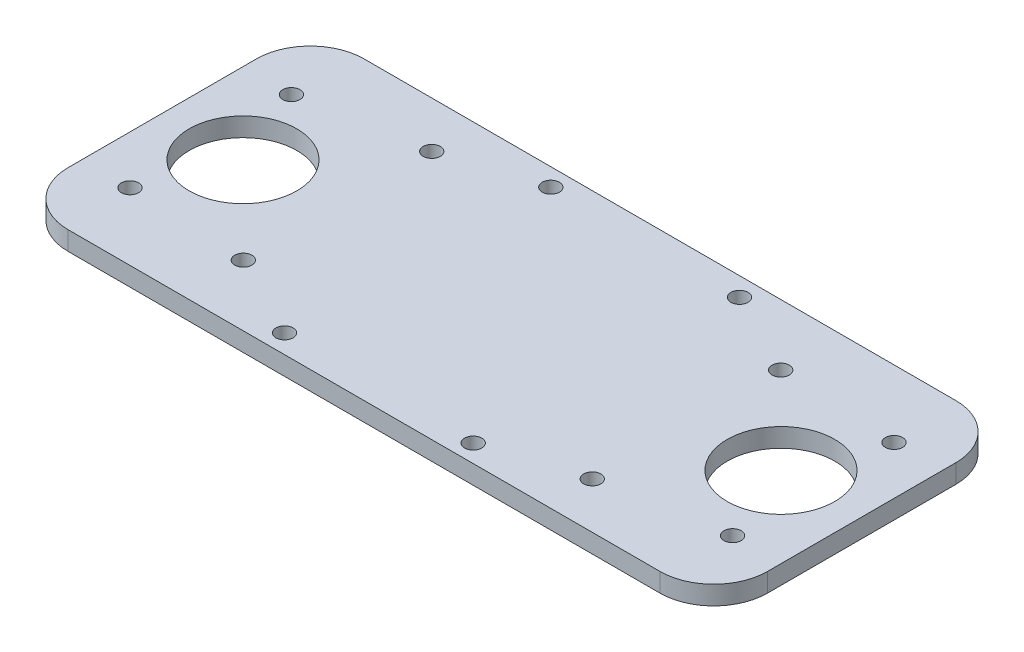
from build123d import *

# Parameters (mm, degrees)
SKETCH1_W           = 130
SKETCH1_H           = 55
SKETCH1_R           = 1.6
SKETCH1_R_2         = 10
BOSS_EXTRUDE3_DEPTH = 3.5
FILLET3_R           = 10


with BuildPart() as part:
    # Sketch1 → Boss-Extrude3 (new body)
    with BuildSketch(Plane(origin=(0, 0, 0), x_dir=(1, 0, 0), z_dir=(0, 1, 0))):
        with Locations((65, -27.5)):
            Rectangle(SKETCH1_W, SKETCH1_H)
        with Locations((9, -12.5)):
            Circle(SKETCH1_R, mode=Mode.SUBTRACT)
        with Locations((9, -42.5)):
            Circle(SKETCH1_R, mode=Mode.SUBTRACT)
        with Locations((121, -42.5)):
            Circle(SKETCH1_R, mode=Mode.SUBTRACT)
        with Locations((121, -12.5)):
            Circle(SKETCH1_R, mode=Mode.SUBTRACT)
        with Locations((15, -27.5)):
            Circle(SKETCH1_R_2, mode=Mode.SUBTRACT)
        with Locations((115, -27.5)):
            Circle(SKETCH1_R_2, mode=Mode.SUBTRACT)
        with Locations((48.016852514, -3.3)):
            Circle(SKETCH1_R, mode=Mode.SUBTRACT)
        with Locations((46.716852514, -51.5)):
            Circle(SKETCH1_R, mode=Mode.SUBTRACT)
        with Locations((98.816852514, -46.4)):
            Circle(SKETCH1_R, mode=Mode.SUBTRACT)
        with Locations((98.816852514, -11.378935708)):
            Circle(SKETCH1_R, mode=Mode.SUBTRACT)
        with Locations((31.183147486, -43.621064292)):
            Circle(SKETCH1_R, mode=Mode.SUBTRACT)
        with Locations((31.183147486, -8.6)):
            Circle(SKETCH1_R, mode=Mode.SUBTRACT)
        with Locations((83.283147486, -3.5)):
            Circle(SKETCH1_R, mode=Mode.SUBTRACT)
        with Locations((81.983147486, -51.7)):
            Circle(SKETCH1_R, mode=Mode.SUBTRACT)
    extrude(amount=BOSS_EXTRUDE3_DEPTH)

    # Fillet3
    fillet3_edges = [part.edges().sort_by_distance(p)[0] for p in [
        (0, 1.75, 0),
        (130, 1.75, 0),
        (130, 1.75, 55),
        (0, 1.75, 55),
    ]]
    fillet(fillet3_edges, radius=FILLET3_R)


solid = part.part
